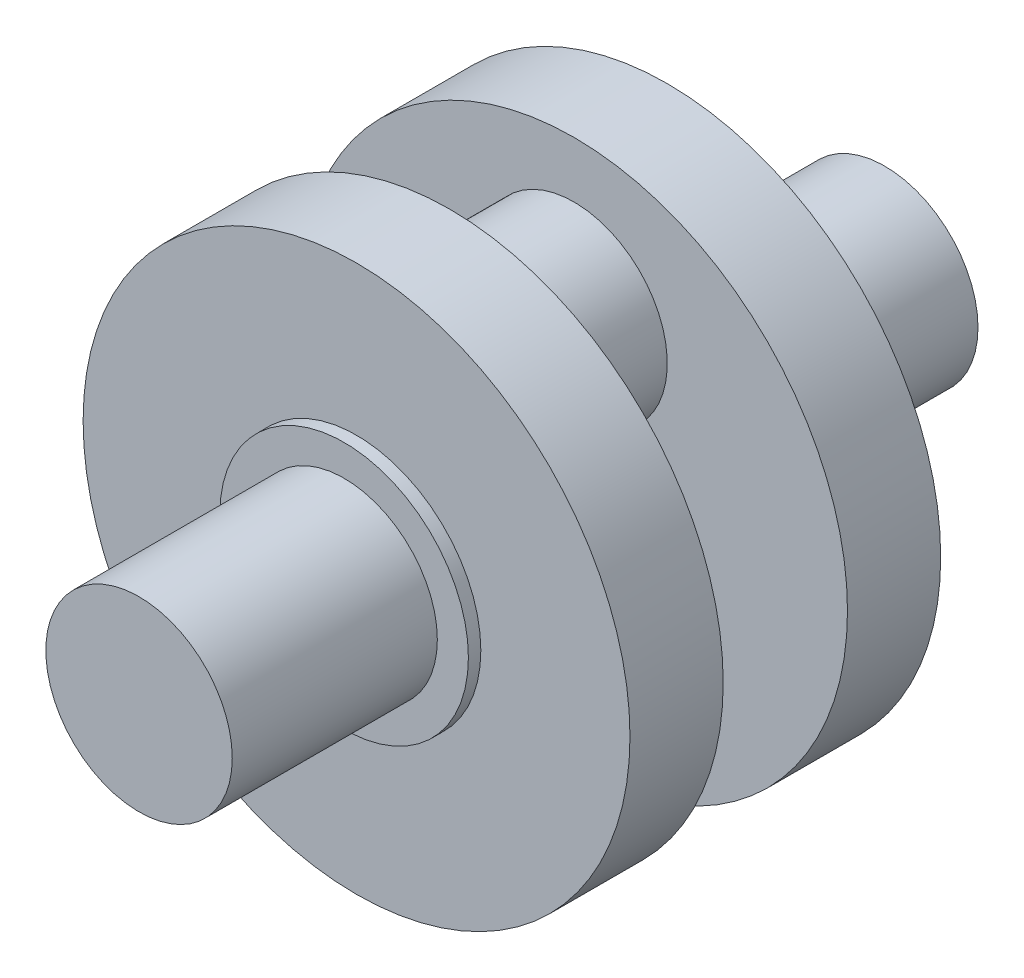
from build123d import *

# Parameters (mm, degrees)
SKETCH1_R           = 15
BOSS_EXTRUDE1_DEPTH = 33
SKETCH4_R           = 20
BOSS_EXTRUDE3_DEPTH = 2
SKETCH6_R           = 44
BOSS_EXTRUDE4_DEPTH = 15
SKETCH7_R           = 15
BOSS_EXTRUDE5_DEPTH = 10


with BuildPart() as part:
    # Sketch1 → Boss-Extrude1 (new body)
    with BuildSketch(Plane.XY):
        Circle(SKETCH1_R)
    extrude(amount=BOSS_EXTRUDE1_DEPTH)

    # Sketch4 → Boss-Extrude3 (add)
    with BuildSketch(Plane.XY):
        Circle(SKETCH4_R)
    extrude(amount=-BOSS_EXTRUDE3_DEPTH)

    # Sketch6 → Boss-Extrude4 (add)
    with BuildSketch(Plane(origin=(0, 0, -2), x_dir=(-1, 0, 0), z_dir=(0, 0, -1))):
        Circle(SKETCH6_R)
    extrude(amount=BOSS_EXTRUDE4_DEPTH)

    # Sketch7 → Boss-Extrude5 (add)
    with BuildSketch(Plane(origin=(0, 0, -17), x_dir=(-1, 0, 0), z_dir=(0, 0, -1))):
        with Locations((0, 20)):
            Circle(SKETCH7_R)
    extrude(amount=BOSS_EXTRUDE5_DEPTH)

    # Mirror1: part across plane


with BuildPart() as part_1:
    add(part.part)
    add(part.part.mirror(Plane(origin=(0, 20, -27), x_dir=(1, 0, 0), z_dir=(0, 0, -1))))


solid = part_1.part
